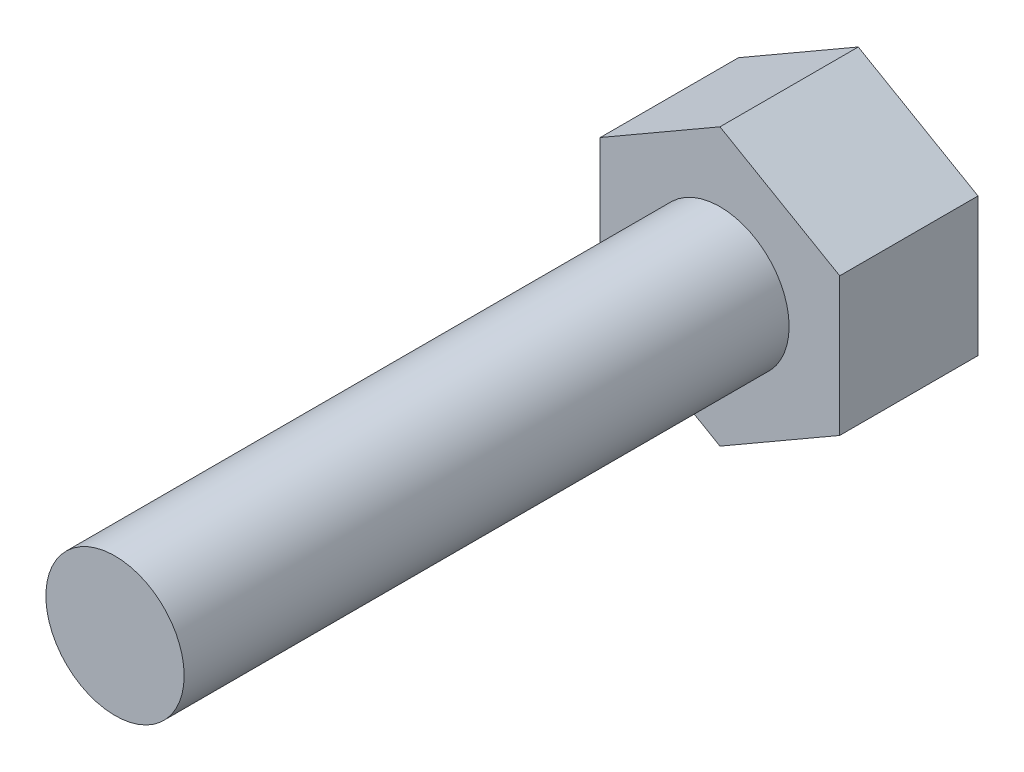
from build123d import *

# Parameters (mm, degrees)
BOSS_EXTRUDE2_DEPTH = 24
SKETCH3_R           = 12
BOSS_EXTRUDE3_DEPTH = 105


with BuildPart() as part:
    # Sketch1 → Boss-Extrude2 (new body)
    with BuildSketch(Plane.XY):
        Polygon((0, 24), (-20.784609691, 12), (-20.784609691, -12), (0, -24), (20.784609691, -12), (20.784609691, 12), align=None)
    extrude(amount=BOSS_EXTRUDE2_DEPTH)

    # Sketch3 → Boss-Extrude3 (add)
    with BuildSketch(Plane.XY.offset(24)):
        Circle(SKETCH3_R)
    extrude(amount=BOSS_EXTRUDE3_DEPTH)


solid = part.part
